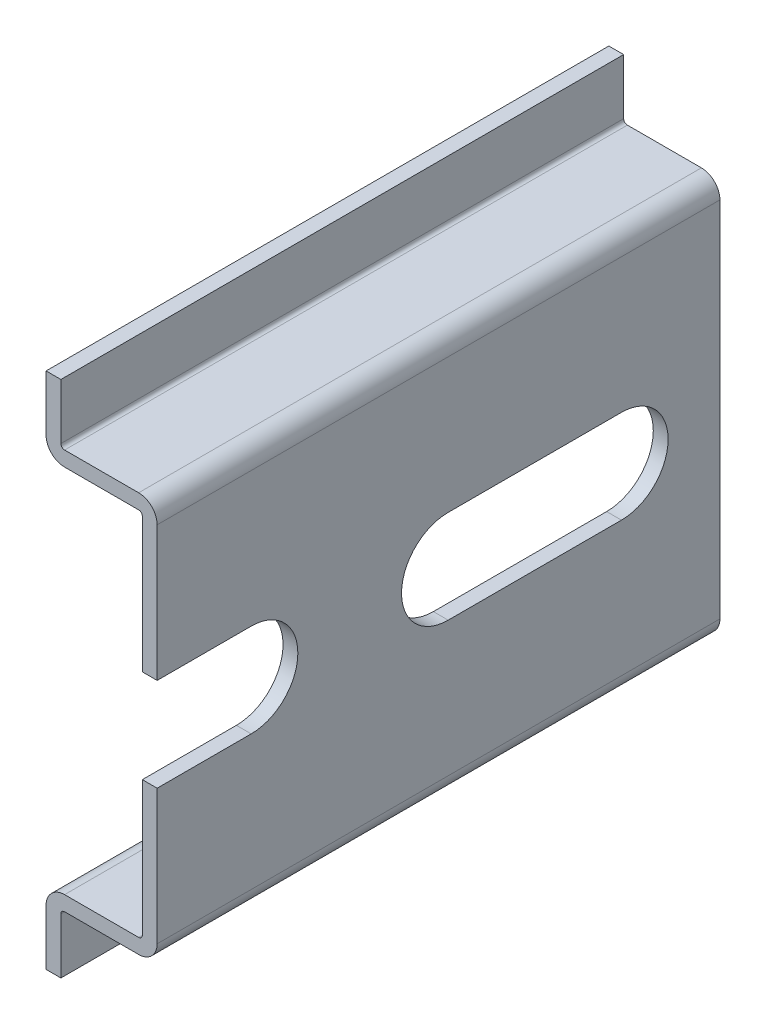
from build123d import *

# Parameters (mm, degrees)
EXTRUDE_THIN1_DEPTH = 50.8
CUT_EXTRUDE1_START  = -8.5
CUT_EXTRUDE1_DEPTH  = 9.5
LPATTERN1_COUNT     = 2
LPATTERN1_PITCH     = 25
FILLET1_R           = 0.25
FILLET2_R           = 1.25
SKETCH5_W           = 12.8
SKETCH5_H           = 35
CUT_EXTRUDE2_DEPTH  = 8.5


with BuildPart() as part:
    # Sketch3 → Extrude-Thin1 (new body)
    with BuildSketch(Plane.XY):
        Polygon((-6.5, 17.5), (-6.5, 13.5), (0, 13.5), (0, -13.5), (-6.5, -13.5), (-6.5, -17.5), (-7.5, -17.5), (-7.5, -12.5), (-1, -12.5), (-1, 12.5), (-7.5, 12.5), (-7.5, 17.5), align=None)
    extrude(amount=EXTRUDE_THIN1_DEPTH)

    # Sketch4 → Cut-Extrude1 (cut)
    with BuildSketch(Plane(origin=(0, 0, 0), x_dir=(0, 0, -1), z_dir=(1, 0, 0)).offset(CUT_EXTRUDE1_START)):
        with BuildLine():
            Line((-6.65, -3.15), (-18.35, -3.15))
            ThreePointArc((-18.35, -3.15), (-21.5, 0), (-18.35, 3.15))
            Line((-18.35, 3.15), (-6.65, 3.15))
            ThreePointArc((-6.65, 3.15), (-3.5, 0), (-6.65, -3.15))
        make_face()
    cut_extrude1 = extrude(amount=CUT_EXTRUDE1_DEPTH, mode=Mode.SUBTRACT)

    # LPattern1: Cut-Extrude1 ×2
    with Locations(*[(0, 0, i * LPATTERN1_PITCH) for i in range(1, LPATTERN1_COUNT)]):
        add(cut_extrude1, mode=Mode.SUBTRACT)

    # Fillet1
    fillet1_edges = [part.edges().sort_by_distance(p)[0] for p in [
        (-6.5, 13.5, 25.4),
        (-6.5, -13.5, 25.4),
        (-1, -12.5, 25.4),
        (-1, 12.5, 25.4),
    ]]
    fillet(fillet1_edges, radius=FILLET1_R)

    # Fillet2
    fillet2_edges = [part.edges().sort_by_distance(p)[0] for p in [
        (0, 13.5, 25.4),
        (0, -13.5, 25.4),
        (-7.5, -12.5, 25.4),
        (-7.5, 12.5, 25.4),
    ]]
    fillet(fillet2_edges, radius=FILLET2_R)

    # Sketch5 → Cut-Extrude2 (cut, through all)
    with BuildSketch(Plane.ZY.offset(7.5)):
        with Locations((44.4, 0)):
            Rectangle(SKETCH5_W, SKETCH5_H)
    extrude(amount=-CUT_EXTRUDE2_DEPTH, mode=Mode.SUBTRACT)


solid = part.part
